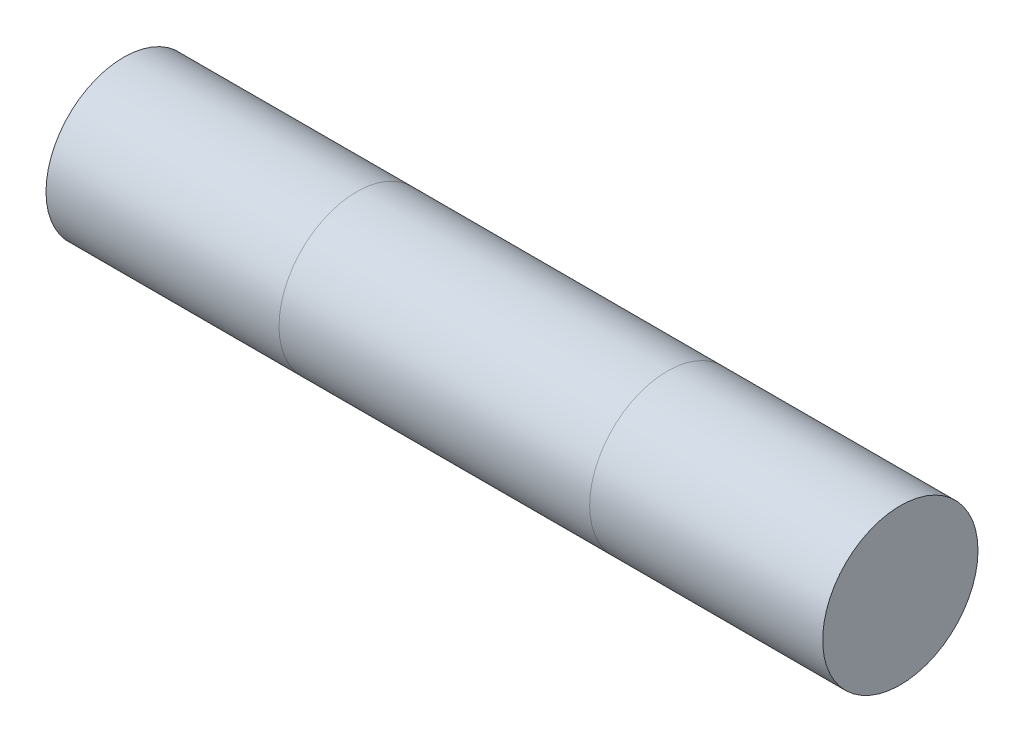
from build123d import *

# Parameters (mm, degrees)
SKIZZE1_R                       = 5
AUFSATZ_LINEAR_AUSTRAGEN1_DEPTH = 25


with BuildPart() as part:
    # Skizze1 → Aufsatz-Linear austragen1 (new body, symmetric)
    with BuildSketch(Plane(origin=(0, 0, 0), x_dir=(0, 0, -1), z_dir=(1, 0, 0))):
        Circle(SKIZZE1_R)
    extrude(amount=AUFSATZ_LINEAR_AUSTRAGEN1_DEPTH, both=True)


solid = part.part
